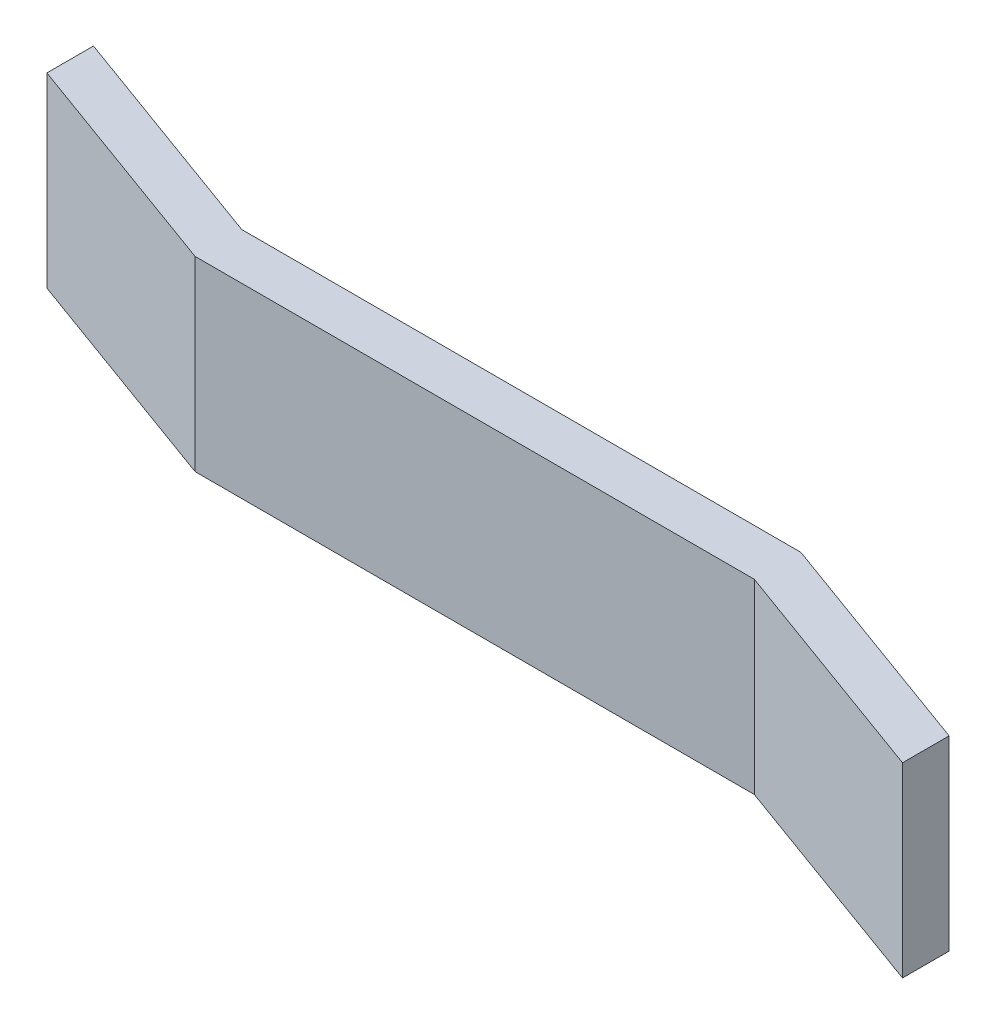
from build123d import *

# Parameters (mm, degrees)
SKETCH_1_W      = 60
SKETCH_1_H      = 5
EXTRUDE_1_DEPTH = 20


with BuildPart() as part:
    # 草图1 → 凸台-拉伸1 (new body)
    with BuildSketch(Plane(origin=(0, 0, 0), x_dir=(1, 0, 0), z_dir=(0, 1, 0))):
        Polygon((-25, 9.099255857), (-25, 14.099255857), (0, 5), (0, 0), align=None)
        with Locations((30, 2.5)):
            Rectangle(SKETCH_1_W, SKETCH_1_H)
        Polygon((60, 0), (85, -9.099255857), (85, -4.099255857), (60, 5), align=None)
    extrude(amount=EXTRUDE_1_DEPTH)


solid = part.part
